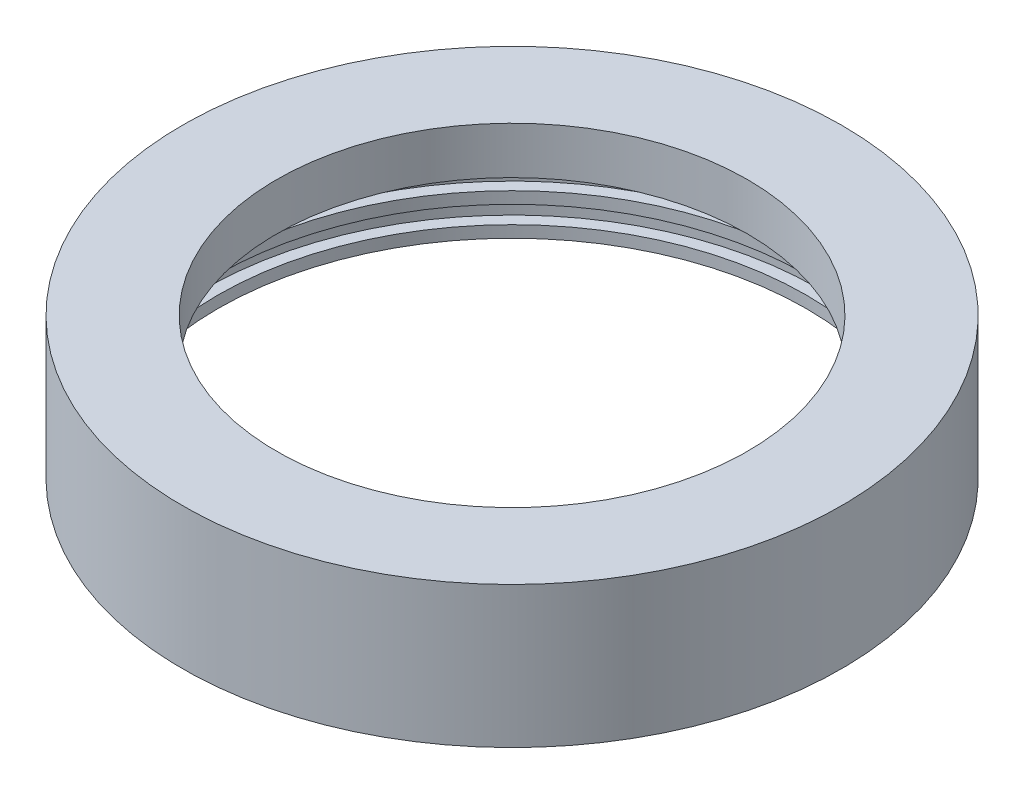
from build123d import *


with BuildPart() as part:
    # Sketch1 → Revolve1 (revolve)
    with BuildSketch(Plane.XY):
        Polygon((63.5, 25.4), (79.375, 25.4), (79.375, 15.875), (82.55, 15.875), (82.55, 11.1125), (79.375, 11.1125), (79.375, 7.9375), (82.55, 7.9375), (82.55, 3.175), (79.375, 3.175), (79.375, 0), (88.9, 0), (88.9, 38.1), (63.5, 38.1), align=None)
    revolve(axis=Axis((0, 0, 0), (0, 1, 0)))


solid = part.part
